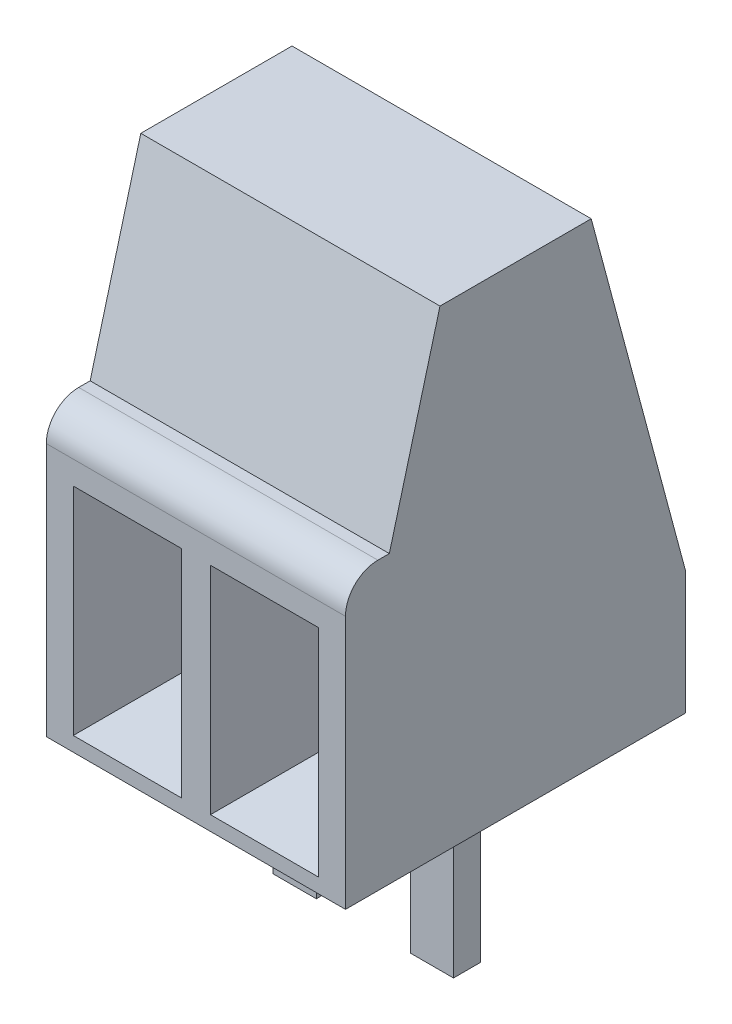
from build123d import *

# Parameters (mm, degrees)
SKETCH1_W           = 5.54
SKETCH1_H           = 6.3
BOSS_EXTRUDE1_DEPTH = 8.8
SKETCH2_W           = 0.8
SKETCH2_H           = 0.5
BOSS_EXTRUDE2_DEPTH = 3.2
CUT_EXTRUDE1_REACH  = 7.54
SKETCH4_W           = 2
SKETCH4_H           = 4
CUT_EXTRUDE2_DEPTH  = 3.15
CUT_EXTRUDE2_TAPER  = 10


with BuildPart() as part:
    # Sketch1 → Boss-Extrude1 (new body)
    with BuildSketch(Plane(origin=(0, 0, 0), x_dir=(1, 0, 0), z_dir=(0, 1, 0))):
        Rectangle(SKETCH1_W, SKETCH1_H)
    extrude(amount=BOSS_EXTRUDE1_DEPTH)

    # Sketch2 → Boss-Extrude2 (add)
    with BuildSketch(Plane(origin=(0, 0, 0), x_dir=(1, 0, 0), z_dir=(0, 1, 0))):
        with Locations((1.27, 0.2)):
            Rectangle(SKETCH2_W, SKETCH2_H)
        with Locations((-1.27, 0.2)):
            Rectangle(SKETCH2_W, SKETCH2_H)
    extrude(amount=-BOSS_EXTRUDE2_DEPTH)

    # Sketch3 → Cut-Extrude1 (cut, up to next)
    with BuildSketch(Plane(origin=(2.77, 0, 0), x_dir=(0, 0, -1), z_dir=(1, 0, 0)), mode=Mode.PRIVATE) as cut_extrude1_sk1:
        with BuildLine():
            ThreePointArc((-3.15, 4.7), (-2.974264069, 5.124264069), (-2.55, 5.3))
            Line((-2.55, 5.3), (-2.337822174, 5.3))
            Line((-2.337822174, 5.3), (-1.4, 8.8))
            Line((-1.4, 8.8), (-3.15, 8.8))
            Line((-3.15, 8.8), (-3.15, 4.7))
        make_face()
    cut_extrude1_tool1 = extrude(cut_extrude1_sk1.sketch, amount=-CUT_EXTRUDE1_REACH, mode=Mode.PRIVATE) & part.part
    add(cut_extrude1_tool1.solids().sort_by_distance((2.77, 7.227986, 2.489914))[0], mode=Mode.SUBTRACT)
    # Sketch3 → Cut-Extrude1 (cut, up to next)
    with BuildSketch(Plane(origin=(2.77, 0, 0), x_dir=(0, 0, -1), z_dir=(1, 0, 0)), mode=Mode.PRIVATE) as cut_extrude1_sk2:
        Polygon((3.15, 8.8), (1.4, 8.8), (3.15, 2.268911087), align=None)
    cut_extrude1_tool2 = extrude(cut_extrude1_sk2.sketch, amount=-CUT_EXTRUDE1_REACH, mode=Mode.PRIVATE) & part.part
    add(cut_extrude1_tool2.solids().sort_by_distance((2.77, 6.62297, -2.566667))[0], mode=Mode.SUBTRACT)

    # Sketch4 → Cut-Extrude2 (cut)
    with BuildSketch(Plane.XY.offset(3.15)):
        with Locations((-1.27, 2.268911087)):
            Rectangle(SKETCH4_W, SKETCH4_H)
        with Locations((1.27, 2.268911087)):
            Rectangle(SKETCH4_W, SKETCH4_H)
    extrude(amount=-CUT_EXTRUDE2_DEPTH, taper=CUT_EXTRUDE2_TAPER, mode=Mode.SUBTRACT)


solid = part.part
